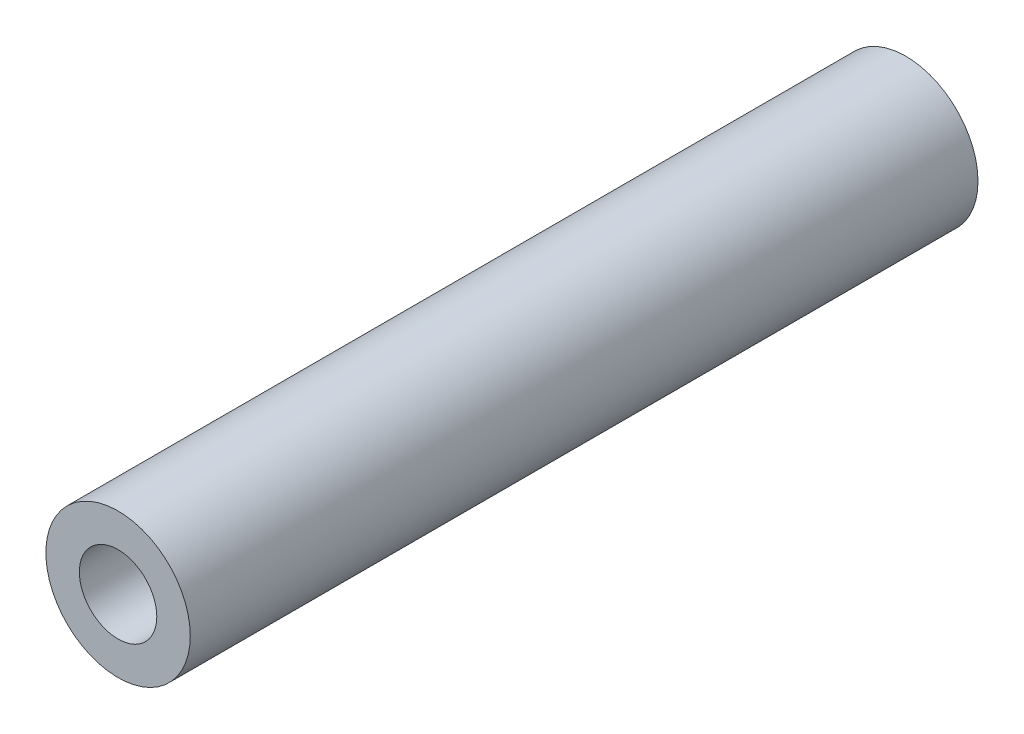
from build123d import *

# Parameters (mm, degrees)
CROQUIS1_R              = 5.5
SALIENTE_EXTRUIR1_DEPTH = 60
CROQUIS6_R              = 2.95
CORTAR_EXTRUIR2_DEPTH   = 15
CROQUIS9_R              = 2.025
CORTAR_EXTRUIR6_DEPTH   = 61


with BuildPart() as part:
    # Croquis1 → Saliente-Extruir1 (new body)
    with BuildSketch(Plane.XY):
        Circle(CROQUIS1_R)
    extrude(amount=SALIENTE_EXTRUIR1_DEPTH)

    # Croquis6 → Cortar-Extruir2 (cut)
    with BuildSketch(Plane.XY.offset(60)):
        Circle(CROQUIS6_R)
    extrude(amount=-CORTAR_EXTRUIR2_DEPTH, mode=Mode.SUBTRACT)

    # Croquis9 → Cortar-Extruir6 (cut, through all)
    with BuildSketch(Plane(origin=(0, 0, 0), x_dir=(-1, 0, 0), z_dir=(0, 0, -1))):
        Circle(CROQUIS9_R)
    extrude(amount=-CORTAR_EXTRUIR6_DEPTH, mode=Mode.SUBTRACT)


solid = part.part
